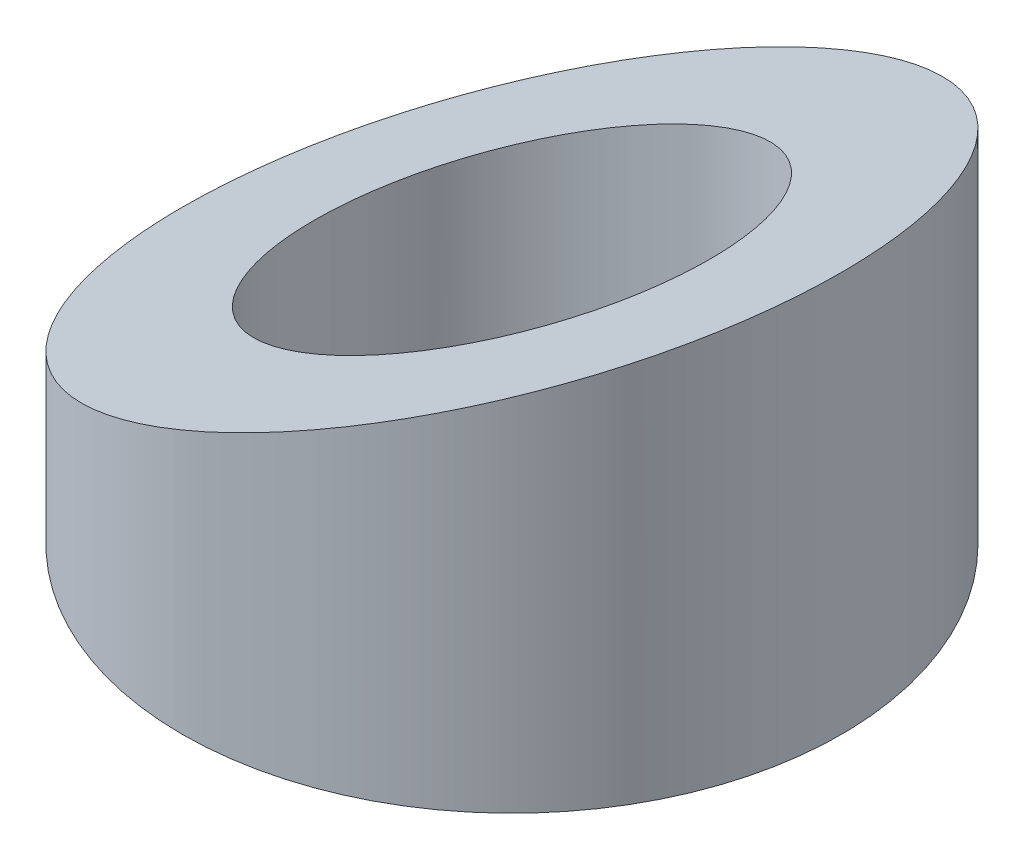
from build123d import *

# Parameters (mm, degrees)
SKETCH_1_R          = 15
EXTRUDE_1_DEPTH     = 20
CUT_EXTRUDE_1_DEPTH = 16.5
SKETCH_7_R          = 9
CUT_EXTRUDE_2_DEPTH = 24.5


with BuildPart() as part:
    # 草图1 → 凸台-拉伸1 (new body)
    with BuildSketch(Plane(origin=(0, 0, 0), x_dir=(1, 0, 0), z_dir=(0, 1, 0))):
        Circle(SKETCH_1_R)
    extrude(amount=EXTRUDE_1_DEPTH)

    # 草图2 → 切除-拉伸1 (cut, symmetric)
    with BuildSketch(Plane.XY):
        Polygon((-15, 5.786796564), (15, 18.213203436), (15, 34.074049074), (-15, 34.074049074), align=None)
    extrude(amount=CUT_EXTRUDE_1_DEPTH, both=True, mode=Mode.SUBTRACT)

    # 草图7 → 切除-拉伸2 (cut)
    with BuildSketch(Plane.XZ):
        Circle(SKETCH_7_R)
    extrude(amount=-CUT_EXTRUDE_2_DEPTH, mode=Mode.SUBTRACT)


solid = part.part
